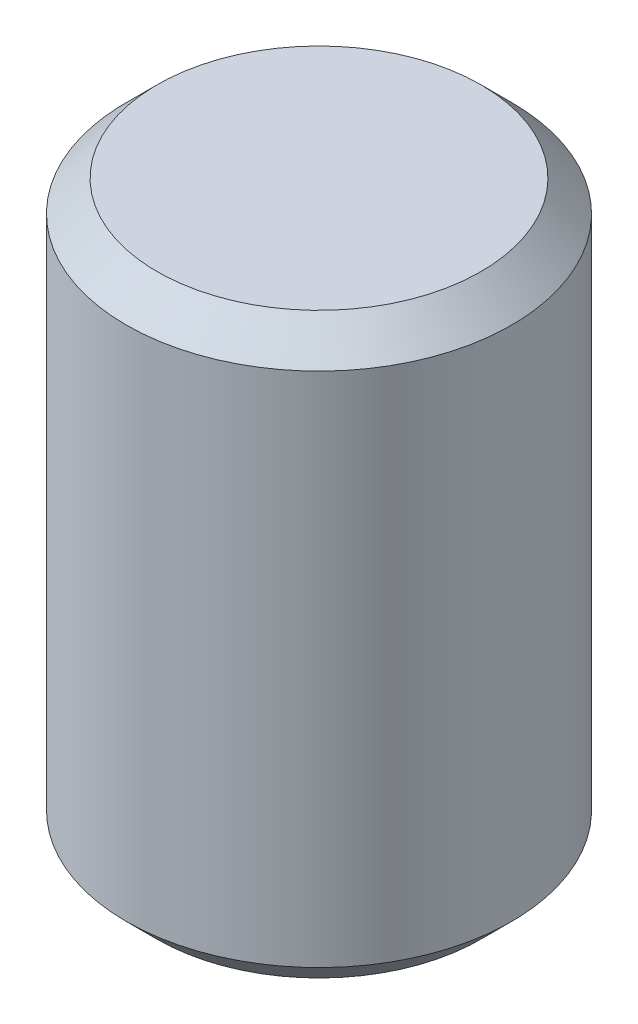
from build123d import *

# Parameters (mm, degrees)
SKETCH1_W     = 3.175
SKETCH1_H     = 9.525
CHAMFER1_SIZE = 0.508


with BuildPart() as part:
    # Sketch1 → Revolve1 (revolve)
    with BuildSketch(Plane.XY):
        with Locations((1.5875, 0)):
            Rectangle(SKETCH1_W, SKETCH1_H)
    revolve(axis=Axis((0, 1.447070913, 0), (0, -1, 0)))

    # Chamfer1
    chamfer1_edges = [part.edges().sort_by_distance(p)[0] for p in [
        (-3.175, -4.7625, 0),
        (-3.175, 4.7625, 0),
    ]]
    chamfer(chamfer1_edges, length=CHAMFER1_SIZE)


solid = part.part
